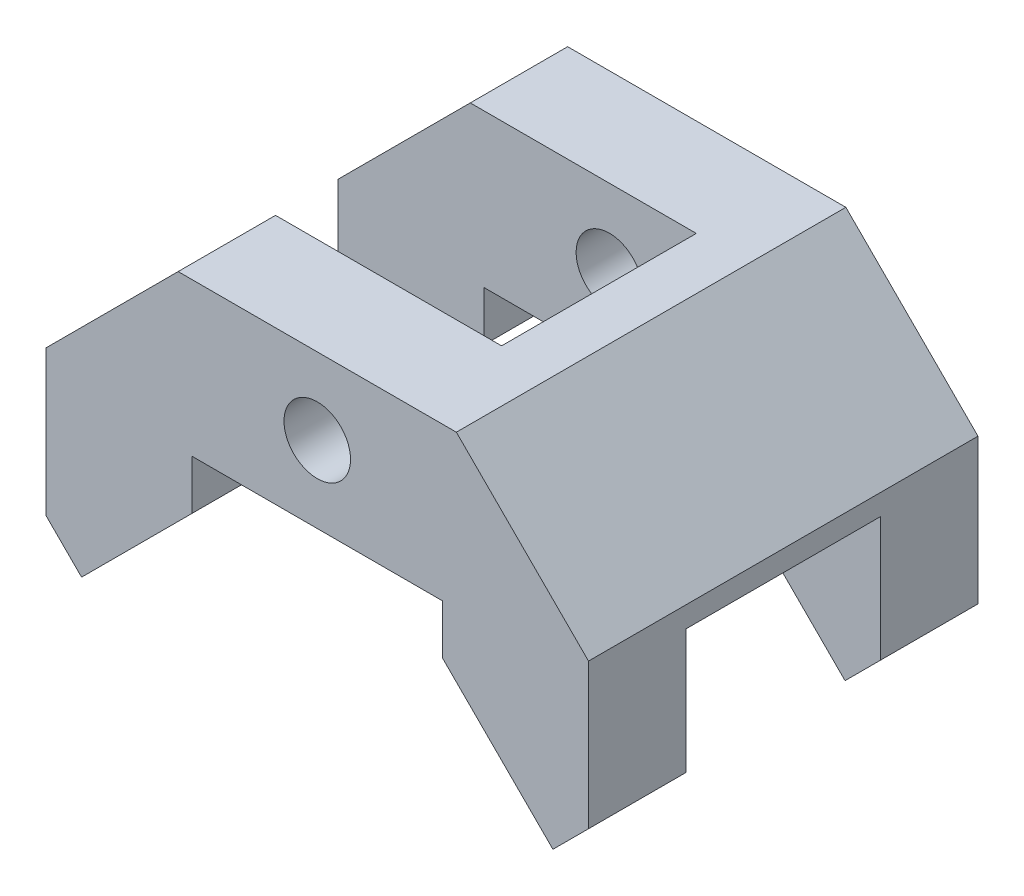
from build123d import *

# Parameters (mm, degrees)
SKETCH_1_R          = 4.781543069
EXTRUDE_1_DEPTH     = 28
SKETCH_2_W          = 51.5
SKETCH_2_H          = 28
CUT_EXTRUDE_1_DEPTH = 45.997474683
SKETCH_3_W          = 28
SKETCH_3_H          = 23.235817225
CUT_EXTRUDE_2_DEPTH = 27.5


with BuildPart() as part:
    # 草图1 → 凸台-拉伸1 (new body, symmetric)
    with BuildSketch(Plane.XY):
        Polygon((0, 0), (-20, 0), (-39, -19), (-39, -39.882250994), (-33.884776311, -44.997474683), (-18, -29.112698372), (-18, -22), (18, -22), (18, -29.112698372), (33.884776311, -44.997474683), (39, -39.882250994), (39, -19), (20, 0), align=None)
        with Locations((0, -11)):
            Circle(SKETCH_1_R, mode=Mode.SUBTRACT)
    extrude(amount=EXTRUDE_1_DEPTH, both=True)

    # 草图2 → 切除-拉伸1 (cut, through all)
    with BuildSketch(Plane(origin=(0, 0, 0), x_dir=(1, 0, 0), z_dir=(0, 1, 0))):
        with Locations((-13.25, 0)):
            Rectangle(SKETCH_2_W, SKETCH_2_H)
    extrude(amount=-CUT_EXTRUDE_1_DEPTH, mode=Mode.SUBTRACT)

    # 草图3 → 切除-拉伸2 (cut, through all)
    with BuildSketch(Plane.ZY.offset(-12.5)):
        with Locations((0, -33.617908613)):
            Rectangle(SKETCH_3_W, SKETCH_3_H)
    extrude(amount=-CUT_EXTRUDE_2_DEPTH, mode=Mode.SUBTRACT)


solid = part.part
